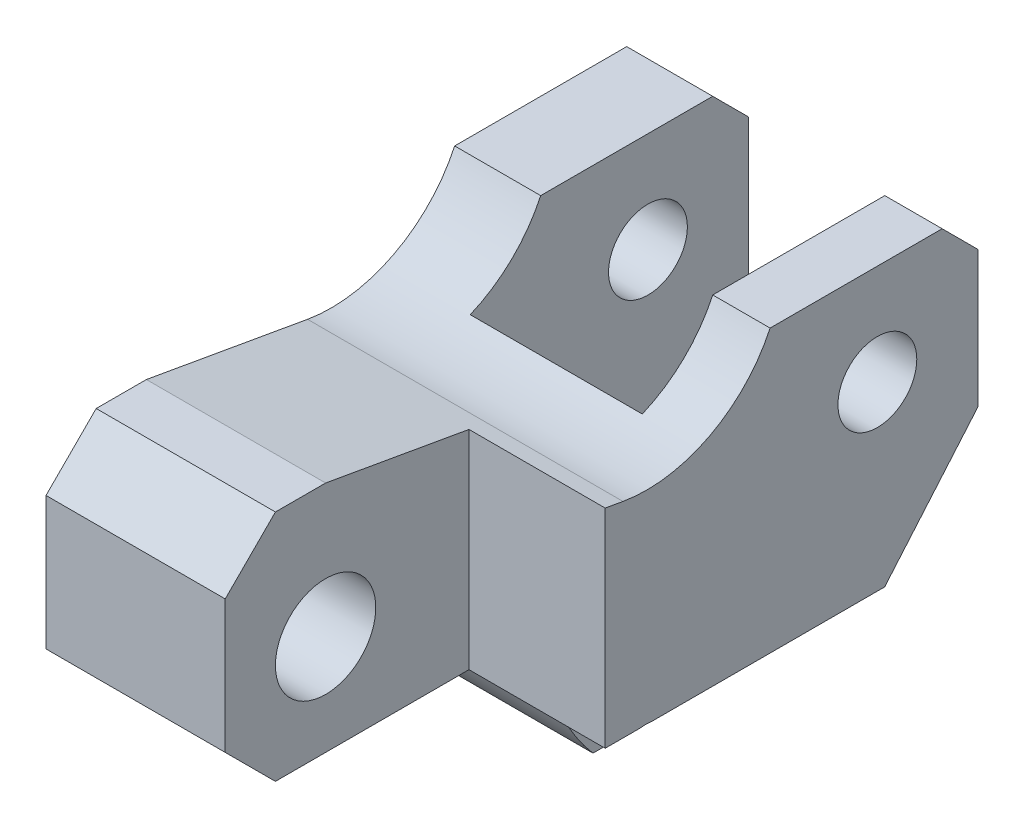
from build123d import *

# Parameters (mm, degrees)
SKETCH1_R               = 7
BOSS_EXTRUDE3_DEPTH     = 22
SKETCH8_R               = 5.5
CUT_EXTRUDE1_DEPTH      = 46
SKETCH10_W              = 34.059077951
SKETCH10_H              = 32.597107019
CUT_EXTRUDE2_DEPTH      = 19
SKETCH19_R              = 41
CUT_EXTRUDE5_DEPTH      = 14
CUT_EXTRUDE5_DEPTH_BACK = 10
SKETCH21_W              = 39.040087977
SKETCH21_H              = 19
CUT_EXTRUDE7_DEPTH      = 19


with BuildPart() as part:
    # Sketch1 → Boss-Extrude3 (new body, symmetric)
    with BuildSketch(Plane(origin=(0, 0, 0), x_dir=(0, 0, -1), z_dir=(1, 0, 0))):
        with BuildLine():
            Line((0, 0), (24, 0))
            Line((24, 0), (29, -5))
            Line((29, -5), (29, -24))
            Line((29, -24), (0, -58))
            Line((0, -58), (-5.703019947, -58))
            ThreePointArc((-5.703019947, -58), (-7.775768892, -55.305839554), (-9.519025669, -52.387647562))
            ThreePointArc((-9.519025669, -52.387647562), (-11.35140658, -48.033040831), (-12.452414435, -43.438696342))
            ThreePointArc((-12.452414435, -43.438696342), (-14.440768413, -40.168970146), (-18.158792561, -39.262903161))
            Line((-18.158792561, -39.262903161), (-50, -39.262903161))
            Line((-50, -39.262903161), (-57, -32.262903161))
            Line((-57, -32.262903161), (-57, -13.71762228))
            Line((-57, -13.71762228), (-50, -6.71762228))
            Line((-50, -6.71762228), (-43, -6.71762228))
            Line((-43, -6.71762228), (-20.519163329, -10.681600334))
            ThreePointArc((-20.519163329, -10.681600334), (-8.446624302, -8.823458857), (0, 0))
        make_face()
        with Locations((-43, -25.262903161)):
            Circle(SKETCH1_R, mode=Mode.SUBTRACT)
    extrude(amount=BOSS_EXTRUDE3_DEPTH, both=True)

    # Sketch8 → Cut-Extrude1 (cut)
    with BuildSketch(Plane(origin=(22, 0, 0), x_dir=(0, 0, -1), z_dir=(1, 0, 0))):
        with Locations((14.962850045, -14)):
            Circle(SKETCH8_R)
    extrude(amount=-CUT_EXTRUDE1_DEPTH, mode=Mode.SUBTRACT)

    # Sketch10 → Cut-Extrude2 (cut)
    with BuildSketch(Plane(origin=(22, 0, 0), x_dir=(0, 0, -1), z_dir=(1, 0, 0))):
        with Locations((-40.029538976, -22.964349652)):
            Rectangle(SKETCH10_W, SKETCH10_H)
    extrude(amount=-CUT_EXTRUDE2_DEPTH, mode=Mode.SUBTRACT)

    # Sketch19 → Cut-Extrude5 (cut, two sides)
    with BuildSketch(Plane(origin=(0, 0, 0), x_dir=(0, 0, -1), z_dir=(1, 0, 0))) as cut_extrude5_sk:
        with Locations((29, 3.701873436)):
            Circle(SKETCH19_R)
    extrude(amount=CUT_EXTRUDE5_DEPTH, mode=Mode.SUBTRACT)
    extrude(cut_extrude5_sk.sketch, amount=-CUT_EXTRUDE5_DEPTH_BACK, mode=Mode.SUBTRACT)

    # Sketch21 → Cut-Extrude7 (cut)
    with BuildSketch(Plane(origin=(22, 0, 0), x_dir=(0, 0, -1), z_dir=(1, 0, 0))):
        with Locations((-3.479956011, -48.762903161)):
            Rectangle(SKETCH21_W, SKETCH21_H)
    extrude(amount=-CUT_EXTRUDE7_DEPTH, mode=Mode.SUBTRACT)


solid = part.part
